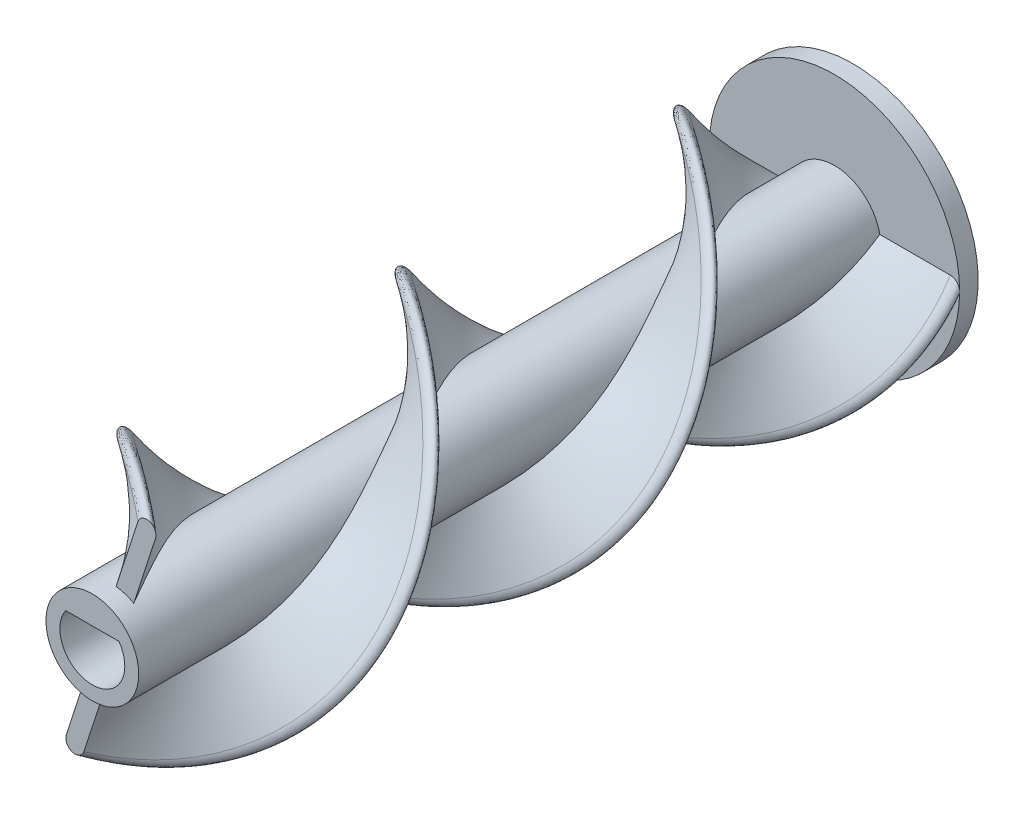
from build123d import *

# Parameters (mm, degrees)
SKETCH1_R           = 5
BOSS_EXTRUDE1_DEPTH = 80
SWEEP1_PITCH        = 60
SWEEP1_HEIGHT       = 78
SWEEP1_RADIUS       = 13.5
SKETCH5_R           = 13.5
BOSS_EXTRUDE2_DEPTH = 2
CUT_EXTRUDE1_DEPTH  = 83


with BuildPart() as part:
    # Sketch1 → Boss-Extrude1 (new body)
    with BuildSketch(Plane.XY):
        Circle(SKETCH1_R)
    extrude(amount=BOSS_EXTRUDE1_DEPTH)

    # Sweep1: sweep along a helix
    with BuildLine() as sweep1_path:
        Helix(SWEEP1_PITCH, SWEEP1_HEIGHT, SWEEP1_RADIUS, center=(0, 0, 0), direction=(0, 0, 1), lefthand=True)
    # Sketch2 → Sweep1 (sweep)
    with BuildSketch(Plane.XY):
        with BuildLine():
            Line((-12.5, 1), (12.5, 1))
            ThreePointArc((12.5, 1), (13.5, 0), (12.5, -1))
            Line((12.5, -1), (-12.5, -1))
            ThreePointArc((-12.5, -1), (-13.5, 0), (-12.5, 1))
        make_face()
    sweep(path=sweep1_path.line, is_frenet=True)

    # Sketch5 → Boss-Extrude2 (add)
    with BuildSketch(Plane(origin=(0, 0, 0), x_dir=(-1, 0, 0), z_dir=(0, 0, -1))):
        Circle(SKETCH5_R)
    extrude(amount=BOSS_EXTRUDE2_DEPTH)

    # Sketch4 → Cut-Extrude1 (cut, through all)
    with BuildSketch(Plane.XY.offset(80)):
        with BuildLine():
            Line((-2.872281323, 2), (2.872281323, 2))
            ThreePointArc((2.872281323, 2), (0, -3.5), (-2.872281323, 2))
        make_face()
    extrude(amount=-CUT_EXTRUDE1_DEPTH, mode=Mode.SUBTRACT)


solid = part.part
